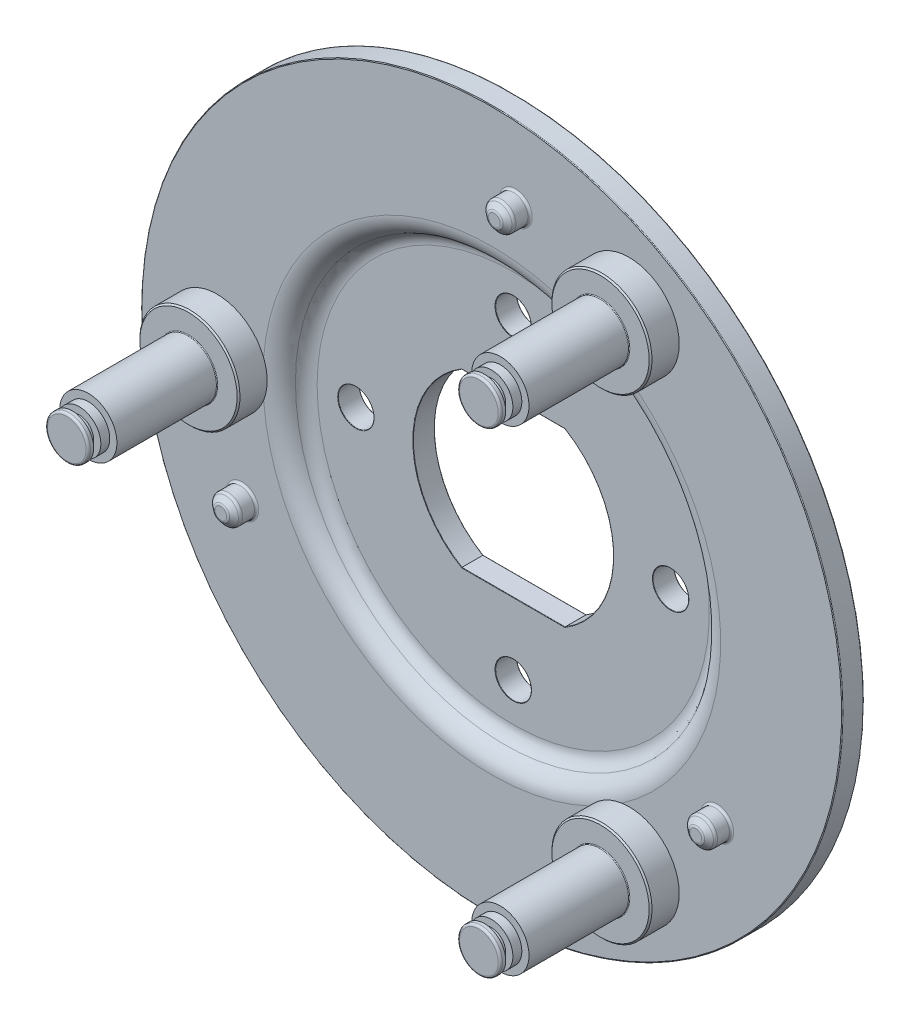
from build123d import *

# Parameters (mm, degrees)
RACCORDO1_R                            = 2
RACCORDO2_R                            = 0.1
TAGLIO_ESTRUSIONE1_DEPTH               = 4.0000001
SCHIZZO16_R                            = 2.5
TAGLIO_ESTRUSIONE2_DEPTH               = 4.0000001
SCHIZZO18_R                            = 0.5
TAGLIO_ESTRUSIONE4_DEPTH               = 5
RIPETIZIONECIRCOLARE1_COUNT            = 3
SCHIZZO19_R                            = 3.5
TAGLIO_ESTRUSIONE5_DEPTH               = 1.5
RIPETIZIONECIRCOLARE2_COUNT            = 3
SCHIZZO22_R                            = 7
ESTRUSIONE_ESTRUSIONE2_DEPTH           = 4
SCHIZZO23_R                            = 4
ESTRUSIONE_ESTRUSIONE3_DEPTH           = 14
RIPETIZIONECIRCOLARE3_COUNT            = 3
SMUSSO1_SIZE                           = 0.2
RACCORDO3_R                            = 0.3
RACCORDO4_R                            = 0.1
SCHIZZO25_R                            = 2
ESTRUSIONE_ESTRUSIONE4_DEPTH           = 3
SMUSSO2_SIZE                           = 0.8
SMUSSO2_SIZE2                          = 1
RACCORDO7_R                            = 0.5
RIPETIZIONECIRCOLARE5_COUNT            = 3
SMUSSO2_OF_RIPETIZIONECIRCOLARE5_SIZE2 = 1
SMUSSO2_OF_RIPETIZIONECIRCOLARE5_SIZE  = 0.8
RACCORDO7_OF_RIPETIZIONECIRCOLARE5_R   = 0.5
RACCORDO8_R                            = 0.05
RACCORDO9_R                            = 0.3


with BuildPart() as part:
    # Schizzo14 → Rivoluzione1 (revolve)
    with BuildSketch(Plane(origin=(0, 0, 0), x_dir=(1, 0, 0), z_dir=(0, 1, 0))):
        with BuildLine():
            Line((0, 6), (29, 6))
            ThreePointArc((29, 6), (29.878679656, 3.878679656), (32, 3))
            Line((32, 3), (49, 3))
            Line((49, 3), (49, 6))
            Line((49, 6), (32, 6))
            ThreePointArc((32, 6), (31.121320344, 8.121320344), (29, 9))
            Line((29, 9), (0, 9))
            Line((0, 9), (0, 6))
        make_face()
    revolve(axis=Axis((0, 0, -9), (0, 0, 1)))

    # Raccordo1
    raccordo1_edges = [part.edges().sort_by_distance(p)[0] for p in [
        (-32, 0, -6),
        (-29, 0, -6),
    ]]
    fillet(raccordo1_edges, radius=RACCORDO1_R)

    # Raccordo2
    raccordo2_edges = [part.edges().sort_by_distance(p)[0] for p in [
        (-49, 0, -6),
        (-49, 0, -3),
    ]]
    fillet(raccordo2_edges, radius=RACCORDO2_R)

    # Schizzo15 → Taglio-Estrusione1 (cut, through all)
    with BuildSketch(Plane.XY.offset(-6)):
        with BuildLine():
            Line((-7.211102551, -12), (7.211102551, -12))
            ThreePointArc((7.211102551, -12), (14, 0), (7.211102551, 12))
            Line((7.211102551, 12), (-7.211102551, 12))
            ThreePointArc((-7.211102551, 12), (-14, 0), (-7.211102551, -12))
        make_face()
    extrude(amount=-TAGLIO_ESTRUSIONE1_DEPTH, mode=Mode.SUBTRACT)

    # Schizzo16 → Taglio-Estrusione2 (cut, through all)
    with BuildSketch(Plane.XY.offset(-6)):
        with Locations((-22, 0)):
            Circle(SCHIZZO16_R)
        with Locations((0, 22)):
            Circle(SCHIZZO16_R)
        with Locations((22, 0)):
            Circle(SCHIZZO16_R)
        with Locations((0, -22)):
            Circle(SCHIZZO16_R)
    extrude(amount=-TAGLIO_ESTRUSIONE2_DEPTH, mode=Mode.SUBTRACT)

    # Schizzo18 → Taglio-Estrusione4 (cut)
    with BuildSketch(Plane.XY.offset(-3)):
        with Locations((3.353655908, 38.332462432)):
            Circle(SCHIZZO18_R)
    taglio_estrusione4 = extrude(amount=-TAGLIO_ESTRUSIONE4_DEPTH, mode=Mode.SUBTRACT)

    # RipetizioneCircolare1: Taglio-Estrusione4 ×3 about axis
    ripetizionecircolare1_axis = Axis((0, 0, 0), (0, 0, 1))
    for i in range(1, RIPETIZIONECIRCOLARE1_COUNT):
        add(taglio_estrusione4.rotate(ripetizionecircolare1_axis, i * 360 / RIPETIZIONECIRCOLARE1_COUNT), mode=Mode.SUBTRACT)

    # Schizzo19 → Taglio-Estrusione5 (cut)
    with BuildSketch(Plane(origin=(0, 0, -6), x_dir=(-1, 0, 0), z_dir=(0, 0, -1))):
        with Locations((-3.353655908, 38.332462432)):
            Circle(SCHIZZO19_R)
        with Locations((34.87371421, -16.261880004)):
            Circle(SCHIZZO19_R)
        with Locations((-31.520058302, -22.070582428)):
            Circle(SCHIZZO19_R)
    extrude(amount=-TAGLIO_ESTRUSIONE5_DEPTH, mode=Mode.SUBTRACT)

    # Schizzo21 → Rivoluzione2 (revolve)
    with BuildSketch(Plane(origin=(0, 0, 0), x_dir=(1, 0, 0), z_dir=(0, 1, 0))):
        with BuildLine():
            Line((-38.9, 6), (-42.4, 6))
            ThreePointArc((-42.4, 6), (-42.753553391, 6.146446609), (-42.9, 6.5))
            Line((-42.9, 6.5), (-42.9, 6.75))
            ThreePointArc((-42.9, 6.75), (-42.753553391, 7.103553391), (-42.4, 7.25))
            Line((-42.4, 7.25), (-40.4, 7.25))
            Line((-40.4, 7.25), (-38.505999788, 6.066249868))
            ThreePointArc((-38.505999788, 6.066249868), (-38.455136503, 6.043599779), (-38.4, 6.035849528))
            Line((-38.4, 6.035849528), (-38.4, 6))
            Line((-38.4, 6), (-38.9, 6))
        make_face()
    rivoluzione2 = revolve(axis=Axis((-38.4, 0, -6), (0, 0, -1)))

    # RipetizioneCircolare2: Rivoluzione2 ×3 about axis
    ripetizionecircolare2_axis = Axis((0, 0, 0), (0, 0, 1))
    for i in range(1, RIPETIZIONECIRCOLARE2_COUNT):
        add(rivoluzione2.rotate(ripetizionecircolare2_axis, i * 360 / RIPETIZIONECIRCOLARE2_COUNT))

    # Schizzo22 → Estrusione-Estrusione2 (add)
    with BuildSketch(Plane.XY.offset(-3)):
        with Locations((-38.4, 0)):
            Circle(SCHIZZO22_R)
    estrusione_estrusione2 = extrude(amount=ESTRUSIONE_ESTRUSIONE2_DEPTH)

    # Schizzo23 → Estrusione-Estrusione3 (add)
    with BuildSketch(Plane.XY.offset(1)):
        with Locations((-38.4, 0)):
            Circle(SCHIZZO23_R)
    estrusione_estrusione3 = extrude(amount=ESTRUSIONE_ESTRUSIONE3_DEPTH)

    # Schizzo24 → Rivoluzione3 (revolve)
    with BuildSketch(Plane(origin=(0, 0, 0), x_dir=(1, 0, 0), z_dir=(0, 1, 0))):
        Polygon((-38.4, -15), (-35.4, -15), (-35.4, -16.25), (-36.4, -16.25), (-36.4, -17.25), (-35.4, -17.25), (-35.4, -18), (-38.4, -18), align=None)
    rivoluzione3 = revolve(axis=Axis((-38.4, 0, 15), (0, 0, 1)))

    # RipetizioneCircolare3: Estrusione-Estrusione2, Estrusione-Estrusione3, Rivoluzione3 ×3 about axis
    ripetizionecircolare3_axis = Axis((0, 0, 0), (0, 0, 1))
    for i in range(1, RIPETIZIONECIRCOLARE3_COUNT):
        add(estrusione_estrusione2.rotate(ripetizionecircolare3_axis, i * 360 / RIPETIZIONECIRCOLARE3_COUNT))
        add(estrusione_estrusione3.rotate(ripetizionecircolare3_axis, i * 360 / RIPETIZIONECIRCOLARE3_COUNT))
        add(rivoluzione3.rotate(ripetizionecircolare3_axis, i * 360 / RIPETIZIONECIRCOLARE3_COUNT))

    # Smusso1
    smusso1_edges = [part.edges().sort_by_distance(p)[0] for p in [
        (-45.4, 0, 1),
        (22.7, 39.317553332, 1),
        (22.7, -39.317553332, 1),
    ]]
    chamfer(smusso1_edges, length=SMUSSO1_SIZE)

    # Raccordo3
    raccordo3_edges = [part.edges().sort_by_distance(p)[0] for p in [
        (-41.4, 0, 18),
        (20.7, 35.853451717, 18),
        (20.7, -35.853451717, 18),
    ]]
    fillet(raccordo3_edges, radius=RACCORDO3_R)

    # Raccordo4
    raccordo4_edges = [part.edges().sort_by_distance(p)[0] for p in [
        (-42.4, 0, 1),
        (21.2, 36.71947712, 1),
        (21.2, -36.71947712, 1),
    ]]
    fillet(raccordo4_edges, radius=RACCORDO4_R)

    # Schizzo25 → Estrusione-Estrusione4 (add)
    with BuildSketch(Plane.XY.offset(-3)):
        with Locations((3.353655908, 38.332462432)):
            Circle(SCHIZZO25_R)
    estrusione_estrusione4 = extrude(amount=ESTRUSIONE_ESTRUSIONE4_DEPTH)

    # Smusso2
    smusso2_edges = [part.edges().sort_by_distance(p)[0] for p in [
        (1.353655908, 38.332462432, 0),
    ]]
    smusso2_side = [part.faces().sort_by_distance(p)[0] for p in [
        (1.353655908, 38.332462432, -1.5),
    ]]
    chamfer(smusso2_edges, length=SMUSSO2_SIZE, length2=SMUSSO2_SIZE2, reference=smusso2_side[0])

    # Raccordo7
    raccordo7_edges = [part.edges().sort_by_distance(p)[0] for p in [
        (2.353655908, 38.332462432, 0),
        (1.353655908, 38.332462432, -0.8),
    ]]
    fillet(raccordo7_edges, radius=RACCORDO7_R)

    # RipetizioneCircolare5: Estrusione-Estrusione4 ×3 about axis
    ripetizionecircolare5_axis = Axis((0, 0, 0), (0, 0, 1))
    for i in range(1, RIPETIZIONECIRCOLARE5_COUNT):
        add(estrusione_estrusione4.rotate(ripetizionecircolare5_axis, i * 360 / RIPETIZIONECIRCOLARE5_COUNT))

    # Smusso2 of RipetizioneCircolare5
    smusso2_of_ripetizionecircolare5_edges = [part.edges().sort_by_distance(p)[0] for p in [
        (-33.87371421, -17.993930812, 0),
        (32.520058302, -20.33853162, 0),
    ]]
    chamfer(smusso2_of_ripetizionecircolare5_edges, length=SMUSSO2_OF_RIPETIZIONECIRCOLARE5_SIZE, length2=SMUSSO2_OF_RIPETIZIONECIRCOLARE5_SIZE2)

    # Raccordo7 of RipetizioneCircolare5
    raccordo7_of_ripetizionecircolare5_edges = [part.edges().sort_by_distance(p)[0] for p in [
        (-34.37371421, -17.127905408, 0),
        (-33.87371421, -17.993930812, -0.8),
        (32.020058302, -21.204557024, 0),
        (32.520058302, -20.33853162, -0.8),
    ]]
    fillet(raccordo7_of_ripetizionecircolare5_edges, radius=RACCORDO7_OF_RIPETIZIONECIRCOLARE5_R)

    # Raccordo8
    raccordo8_edges = [part.edges().sort_by_distance(p)[0] for p in [
        (14, 0, -9),
        (7.211102551, 12, -7.5),
        (0, -12, -9),
        (7.211102551, -12, -7.5),
        (-14, 0, -9),
        (0, 12, -9),
        (14, 0, -6),
        (0, 12, -6),
        (-14, 0, -6),
        (0, -12, -6),
        (-24.5, 0, -9),
        (-24.5, 0, -6),
        (-2.5, 22, -9),
        (-2.5, 22, -6),
        (19.5, 0, -9),
        (19.5, 0, -6),
        (-2.5, -22, -9),
        (-2.5, -22, -6),
    ]]
    fillet(raccordo8_edges, radius=RACCORDO8_R)

    # Raccordo9
    raccordo9_edges = [part.edges().sort_by_distance(p)[0] for p in [
        (1.353655908, 38.332462432, -3),
        (32.520058302, -20.33853162, -3),
        (-33.87371421, -17.993930812, -3),
    ]]
    fillet(raccordo9_edges, radius=RACCORDO9_R)


solid = part.part
